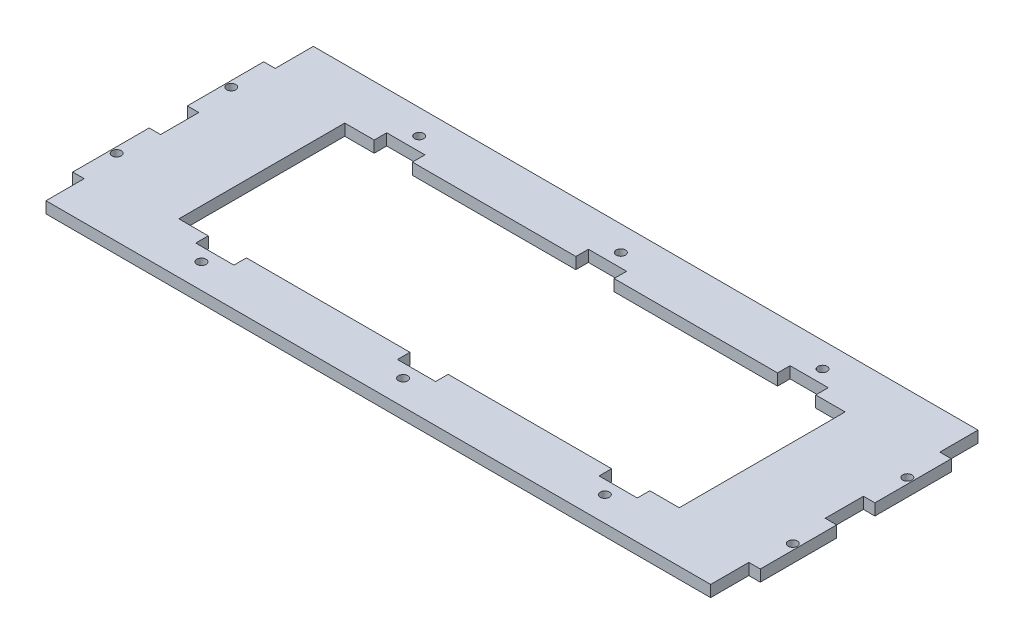
from build123d import *

# Parameters (mm, degrees)
SKETCH1_R           = 1.524
BOSS_EXTRUDE1_DEPTH = 3.81


with BuildPart() as part:
    # Sketch1 → Boss-Extrude1 (new body)
    with BuildSketch(Plane(origin=(0, 0, 0), x_dir=(1, 0, 0), z_dir=(0, 1, 0))):
        Polygon((-110.49, -44.45), (110.49, -44.45), (110.49, -31.75), (114.3, -31.75), (114.3, -6.35), (110.49, -6.35), (110.49, 6.35), (114.3, 6.35), (114.3, 31.75), (110.49, 31.75), (110.49, 44.45), (-110.49, 44.45), (-110.49, 31.75), (-114.3, 31.75), (-114.3, 6.35), (-110.49, 6.35), (-110.49, -6.35), (-114.3, -6.35), (-114.3, -31.75), (-110.49, -31.75), align=None)
        with Locations((112.395, 19.05)):
            Circle(SKETCH1_R, mode=Mode.SUBTRACT)
        with Locations((-112.395, 19.05)):
            Circle(SKETCH1_R, mode=Mode.SUBTRACT)
        with Locations((-112.395, -19.05)):
            Circle(SKETCH1_R, mode=Mode.SUBTRACT)
        with Locations((112.395, -19.05)):
            Circle(SKETCH1_R, mode=Mode.SUBTRACT)
        with Locations((-67.056, -36.195)):
            Circle(SKETCH1_R, mode=Mode.SUBTRACT)
        with Locations((0, -36.195)):
            Circle(SKETCH1_R, mode=Mode.SUBTRACT)
        with Locations((67.056, -36.195)):
            Circle(SKETCH1_R, mode=Mode.SUBTRACT)
        with Locations((67.056, 36.195)):
            Circle(SKETCH1_R, mode=Mode.SUBTRACT)
        with Locations((-67.056, 36.195)):
            Circle(SKETCH1_R, mode=Mode.SUBTRACT)
        with Locations((0, 36.195)):
            Circle(SKETCH1_R, mode=Mode.SUBTRACT)
        Polygon((-83.185, -27.5844), (-73.406, -27.5844), (-73.406, -31.75), (-60.706, -31.75), (-60.706, -27.5844), (-6.35, -27.5844), (-6.35, -31.75), (6.35, -31.75), (6.35, -27.5844), (60.706, -27.5844), (60.706, -31.75), (73.406, -31.75), (73.406, -27.5844), (83.185, -27.5844), (83.185, 27.5844), (73.406, 27.5844), (73.406, 31.75), (60.706, 31.75), (60.706, 27.5844), (6.35, 27.5844), (6.35, 31.75), (-6.35, 31.75), (-6.35, 27.5844), (-60.706, 27.5844), (-60.706, 31.75), (-73.406, 31.75), (-73.406, 27.5844), (-83.185, 27.5844), align=None, mode=Mode.SUBTRACT)
    extrude(amount=BOSS_EXTRUDE1_DEPTH)


solid = part.part
